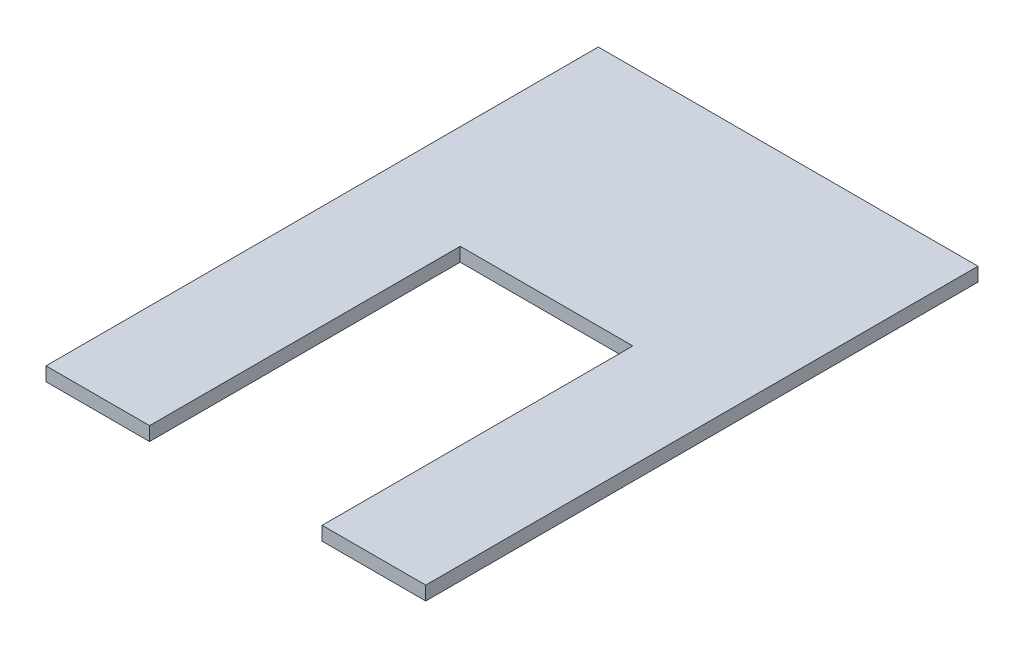
from build123d import *

# Parameters (mm, degrees)
SKETCH1_W           = 69.85
SKETCH1_H           = 101.6
BOSS_EXTRUDE1_DEPTH = 2.54
SKETCH2_W           = 31.75
SKETCH2_H           = 57.15
CUT_EXTRUDE1_DEPTH  = 2.54


with BuildPart() as part:
    # Sketch1 → Boss-Extrude1 (new body)
    with BuildSketch(Plane(origin=(0, 0, 0), x_dir=(1, 0, 0), z_dir=(0, 1, 0))):
        with Locations((34.925, 50.8)):
            Rectangle(SKETCH1_W, SKETCH1_H)
    extrude(amount=BOSS_EXTRUDE1_DEPTH)

    # Sketch2 → Cut-Extrude1 (cut)
    with BuildSketch(Plane(origin=(0, 2.54, 0), x_dir=(1, 0, 0), z_dir=(0, 1, 0))):
        with Locations((34.925, 28.575)):
            Rectangle(SKETCH2_W, SKETCH2_H)
    extrude(amount=-CUT_EXTRUDE1_DEPTH, mode=Mode.SUBTRACT)


solid = part.part
